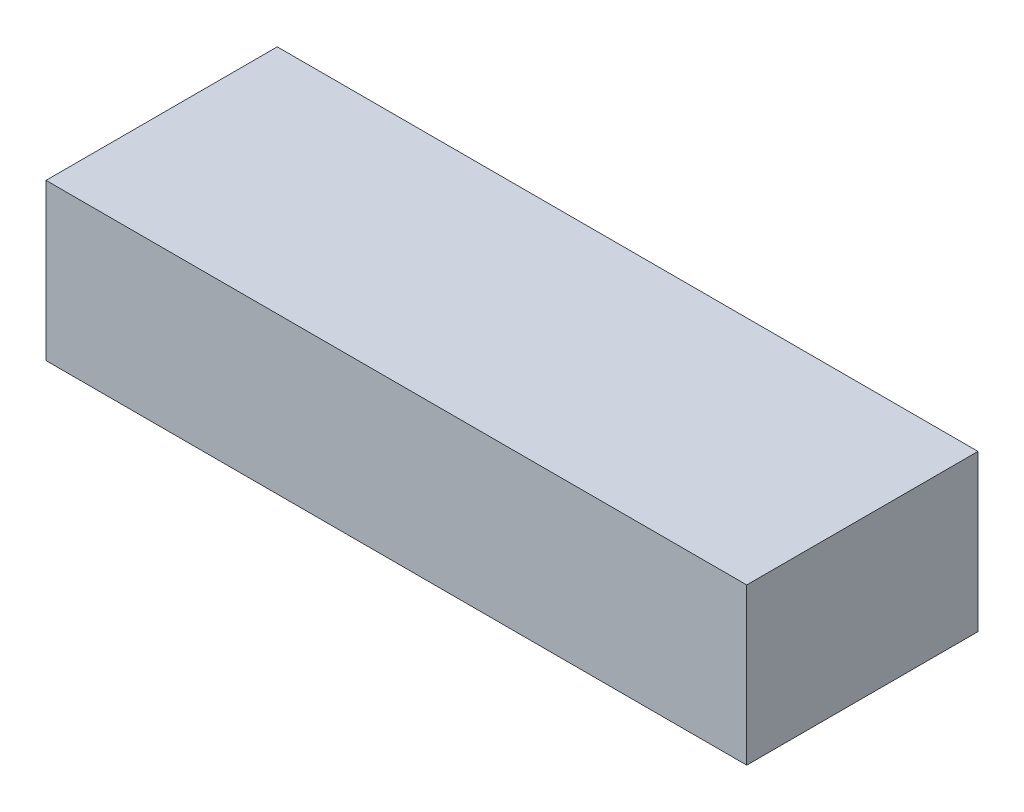
from build123d import *

# Parameters (mm, degrees)
SKETCH1_W           = 153.924
SKETCH1_H           = 50.8
BOSS_EXTRUDE1_DEPTH = 34.29


with BuildPart() as part:
    # Sketch1 → Boss-Extrude1 (new body)
    with BuildSketch(Plane(origin=(0, 0, 0), x_dir=(1, 0, 0), z_dir=(0, 1, 0))):
        Rectangle(SKETCH1_W, SKETCH1_H)
    extrude(amount=BOSS_EXTRUDE1_DEPTH)


solid = part.part
